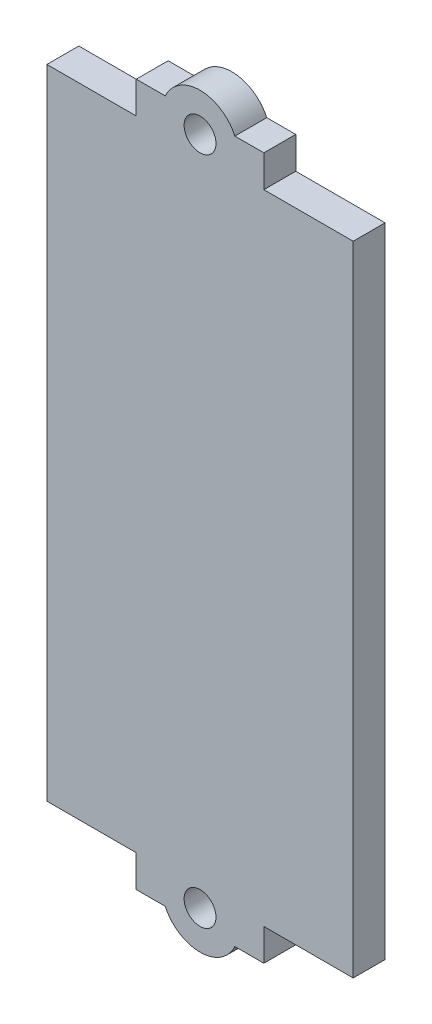
from build123d import *

# Parameters (mm, degrees)
SKETCH1_W           = 48
SKETCH1_H           = 100
BOSS_EXTRUDE1_DEPTH = 5
SKETCH2_W           = 20
SKETCH2_H           = 5
BOSS_EXTRUDE2_DEPTH = 5
SKETCH3_R           = 6
BOSS_EXTRUDE3_DEPTH = 5
SKETCH4_R           = 2.5
CUT_EXTRUDE1_DEPTH  = 5


with BuildPart() as part:
    # Sketch1 → Boss-Extrude1 (new body)
    with BuildSketch(Plane.XY):
        Rectangle(SKETCH1_W, SKETCH1_H)
    extrude(amount=BOSS_EXTRUDE1_DEPTH)

    # Sketch2 → Boss-Extrude2 (add)
    with BuildSketch(Plane(origin=(0, 50, 0), x_dir=(1, 0, 0), z_dir=(0, 1, 0))):
        with Locations((0, -2.5)):
            Rectangle(SKETCH2_W, SKETCH2_H)
    boss_extrude2 = extrude(amount=BOSS_EXTRUDE2_DEPTH)

    # Mirror1: Boss-Extrude2 across plane
    add(boss_extrude2.mirror(Plane.ZX))

    # Sketch3 → Boss-Extrude3 (add)
    with BuildSketch(Plane.XY.offset(5)):
        with Locations((0, 52.5)):
            Circle(SKETCH3_R)
    boss_extrude3 = extrude(amount=-BOSS_EXTRUDE3_DEPTH)

    # Sketch4 → Cut-Extrude1 (cut)
    with BuildSketch(Plane.XY.offset(5)):
        with Locations((0, 52.5)):
            Circle(SKETCH4_R)
    cut_extrude1 = extrude(amount=-CUT_EXTRUDE1_DEPTH, mode=Mode.SUBTRACT)

    # Mirror2: Boss-Extrude3, Cut-Extrude1 across plane
    add(boss_extrude3.mirror(Plane.ZX))
    add(cut_extrude1.mirror(Plane.ZX), mode=Mode.SUBTRACT)


solid = part.part
